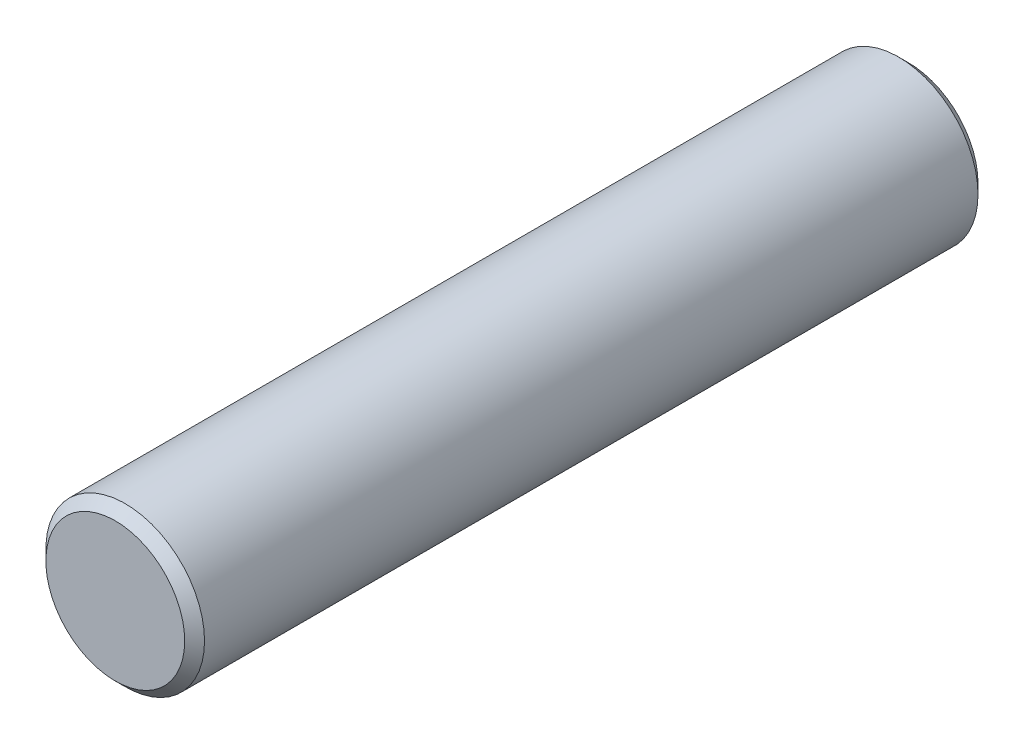
from build123d import *

# Parameters (mm, degrees)
CROQUIS1_R              = 4
SALIENTE_EXTRUIR1_DEPTH = 20
CHAFL_N1_SIZE           = 0.5


with BuildPart() as part:
    # Croquis1 → Saliente-Extruir1 (new body, symmetric)
    with BuildSketch(Plane.XY):
        Circle(CROQUIS1_R)
    extrude(amount=SALIENTE_EXTRUIR1_DEPTH, both=True)

    # Chaflán1
    chafl_n1_edges = [part.edges().sort_by_distance(p)[0] for p in [
        (-4, 0, -20),
        (-4, 0, 20),
    ]]
    chamfer(chafl_n1_edges, length=CHAFL_N1_SIZE)


solid = part.part
